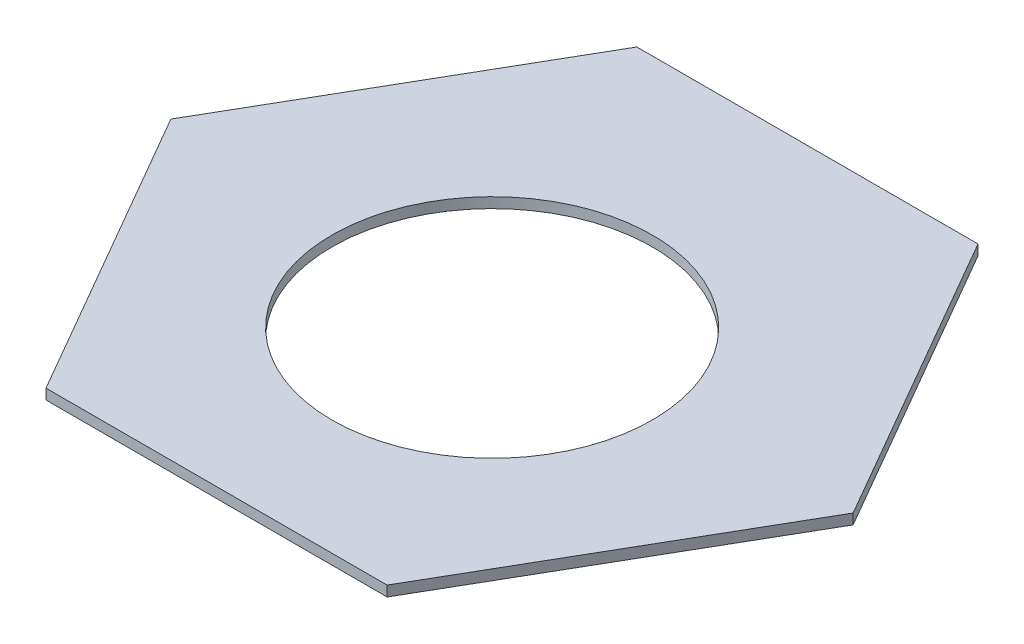
from build123d import *

# Parameters (mm, degrees)
SKETCH1_R           = 77.5
BOSS_EXTRUDE1_DEPTH = 5


with BuildPart() as part:
    # Sketch1 → Boss-Extrude1 (new body)
    with BuildSketch(Plane(origin=(0, 0, 0), x_dir=(1, 0, 0), z_dir=(0, 1, 0))):
        Polygon((165, 0), (82.5, 142.894191624), (-82.5, 142.894191624), (-165, 0), (-82.5, -142.894191624), (82.5, -142.894191624), align=None)
        with Locations((0, -9.605808376)):
            Circle(SKETCH1_R, mode=Mode.SUBTRACT)
    extrude(amount=BOSS_EXTRUDE1_DEPTH)


solid = part.part
